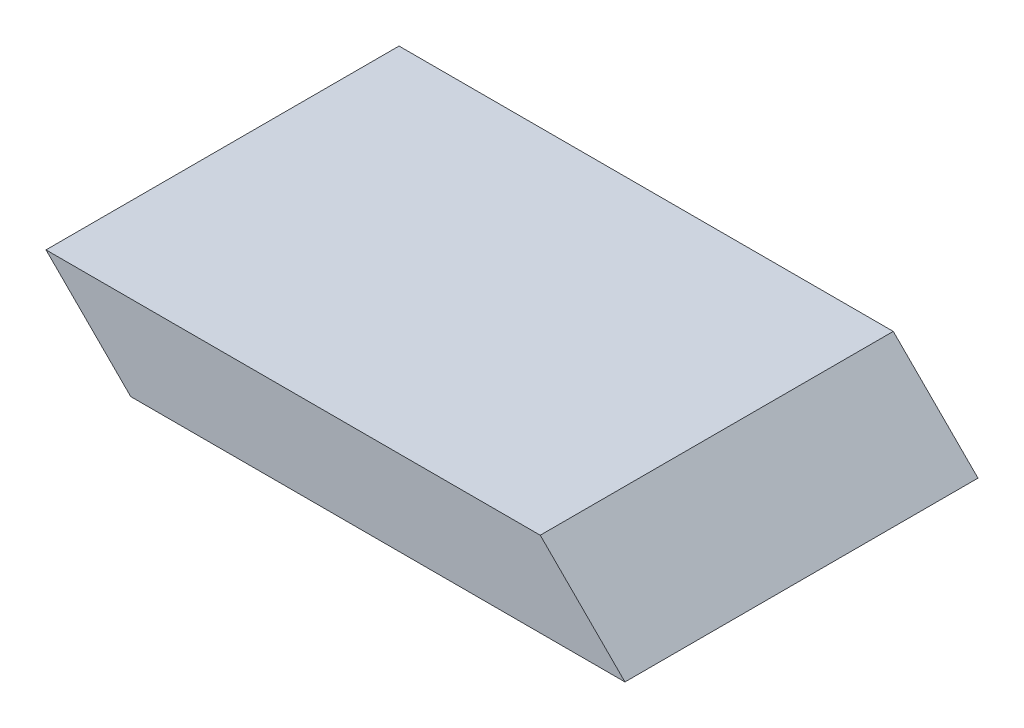
from build123d import *

# Parameters (mm, degrees)
SKETCH1_W           = 88.9
SKETCH1_H           = 63.5
BOSS_EXTRUDE1_DEPTH = 15.24
BOSS_EXTRUDE2_DEPTH = 63.5
CUT_EXTRUDE1_DEPTH  = 63.5


with BuildPart() as part:
    # Sketch1 → Boss-Extrude1 (new body)
    with BuildSketch(Plane(origin=(0, 0, 0), x_dir=(1, 0, 0), z_dir=(0, 1, 0))):
        Rectangle(SKETCH1_W, SKETCH1_H)
    extrude(amount=BOSS_EXTRUDE1_DEPTH)

    # Sketch2 → Boss-Extrude2 (add)
    with BuildSketch(Plane.XY.offset(31.75)):
        Polygon((44.45, 15.24), (59.69, 0), (44.45, 0), align=None)
    extrude(amount=-BOSS_EXTRUDE2_DEPTH)

    # Sketch3 → Cut-Extrude1 (cut)
    with BuildSketch(Plane(origin=(0, 0, -31.75), x_dir=(-1, 0, 0), z_dir=(0, 0, -1))):
        Polygon((44.45, 15.24), (29.21, 0), (44.45, 0), align=None)
    extrude(amount=-CUT_EXTRUDE1_DEPTH, mode=Mode.SUBTRACT)


solid = part.part
